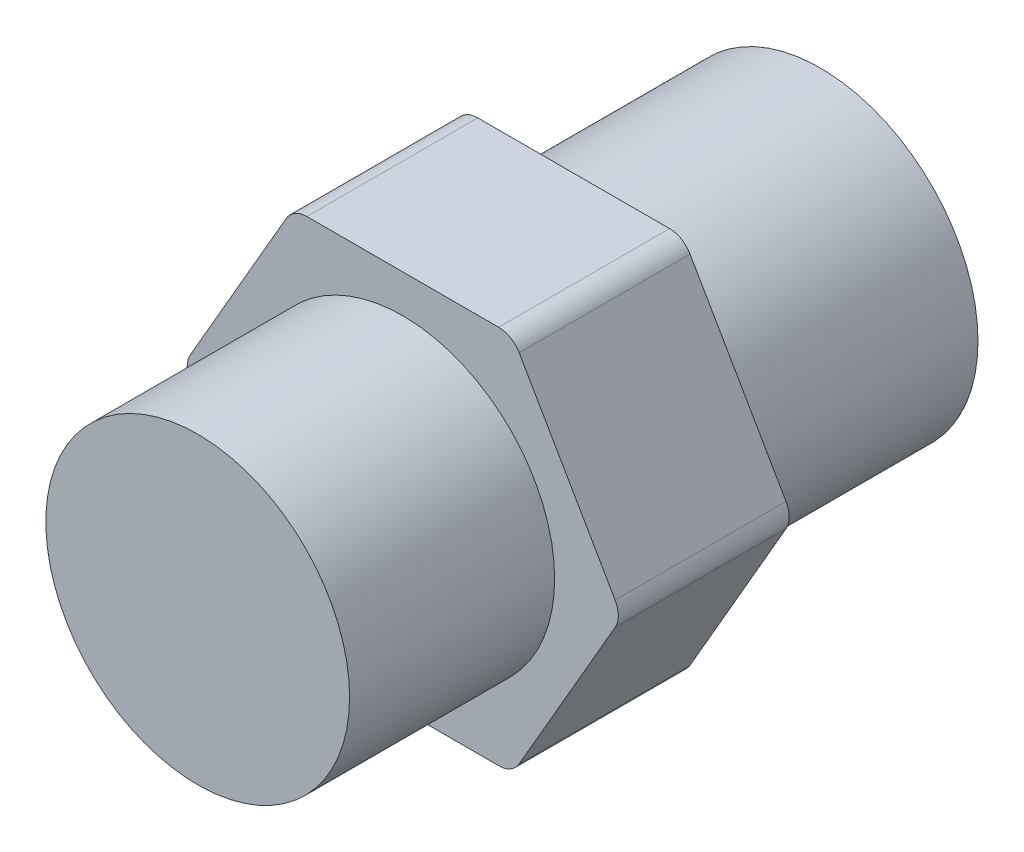
from build123d import *

# Parameters (mm, degrees)
BOSS_EXTRUDE1_DEPTH = 11.43
BOSS_EXTRUDE2_DEPTH = 6.35
SKETCH6_R           = 10.16
BOSS_EXTRUDE3_DEPTH = 13.716
SKETCH7_R           = 10.541
BOSS_EXTRUDE4_DEPTH = 16.51
FILLET1_R           = 1.5875
FILLET2_R           = 1.5875


with BuildPart() as part:
    # Sketch1 → Boss-Extrude1 (new body)
    with BuildSketch(Plane.XY):
        Polygon((14.664696837, 0), (7.332348419, 12.7), (-7.332348419, 12.7), (-14.664696837, 0), (-7.332348419, -12.7), (7.332348419, -12.7), align=None)
    extrude(amount=BOSS_EXTRUDE1_DEPTH)

    # Sketch4 → Boss-Extrude2 (add)
    with BuildSketch(Plane(origin=(-10.998522628, -6.35, 0), x_dir=(0, 0, 1), z_dir=(-0.866025404, -0.5, 0))):
        Polygon((5.715, 0), (5.715, 5.572584798), (0.889, 2.786292399), (0.889, 0), align=None)
        Polygon((5.715, -5.572584798), (5.715, 0), (0.889, 0), (0.889, -2.786292399), align=None)
        Polygon((10.541, 0), (5.715, 0), (5.715, -5.572584798), (10.541, -2.786292399), align=None)
        Polygon((10.541, 2.786292399), (5.715, 5.572584798), (5.715, 0), (10.541, 0), align=None)
    extrude(amount=BOSS_EXTRUDE2_DEPTH)

    # Sketch6 → Boss-Extrude3 (add)
    with BuildSketch(Plane.XY.offset(11.43)):
        Circle(SKETCH6_R)
    extrude(amount=BOSS_EXTRUDE3_DEPTH)

    # Sketch7 → Boss-Extrude4 (add)
    with BuildSketch(Plane(origin=(0, 0, 0), x_dir=(-1, 0, 0), z_dir=(0, 0, -1))):
        Circle(SKETCH7_R)
    extrude(amount=BOSS_EXTRUDE4_DEPTH)

    # Fillet1
    fillet1_edges = [part.edges().sort_by_distance(p)[0] for p in [
        (7.332348419, -12.7, 5.715),
        (-7.332348419, -12.7, 5.715),
        (-14.664696837, 0, 5.715),
        (-7.332348419, 12.7, 5.715),
        (7.332348419, 12.7, 5.715),
        (14.664696837, 0, 5.715),
    ]]
    fillet(fillet1_edges, radius=FILLET1_R)

    # Fillet2
    fillet2_edges = [part.edges().sort_by_distance(p)[0] for p in [
        (-12.355007086, -10.3505, 0.889),
        (-10.961860886, -12.7635, 5.715),
        (-12.355007086, -10.3505, 10.541),
        (-15.141299485, -5.5245, 10.541),
        (-16.534445684, -3.1115, 5.715),
        (-15.141299485, -5.5245, 0.889),
    ]]
    fillet(fillet2_edges, radius=FILLET2_R)


solid = part.part
